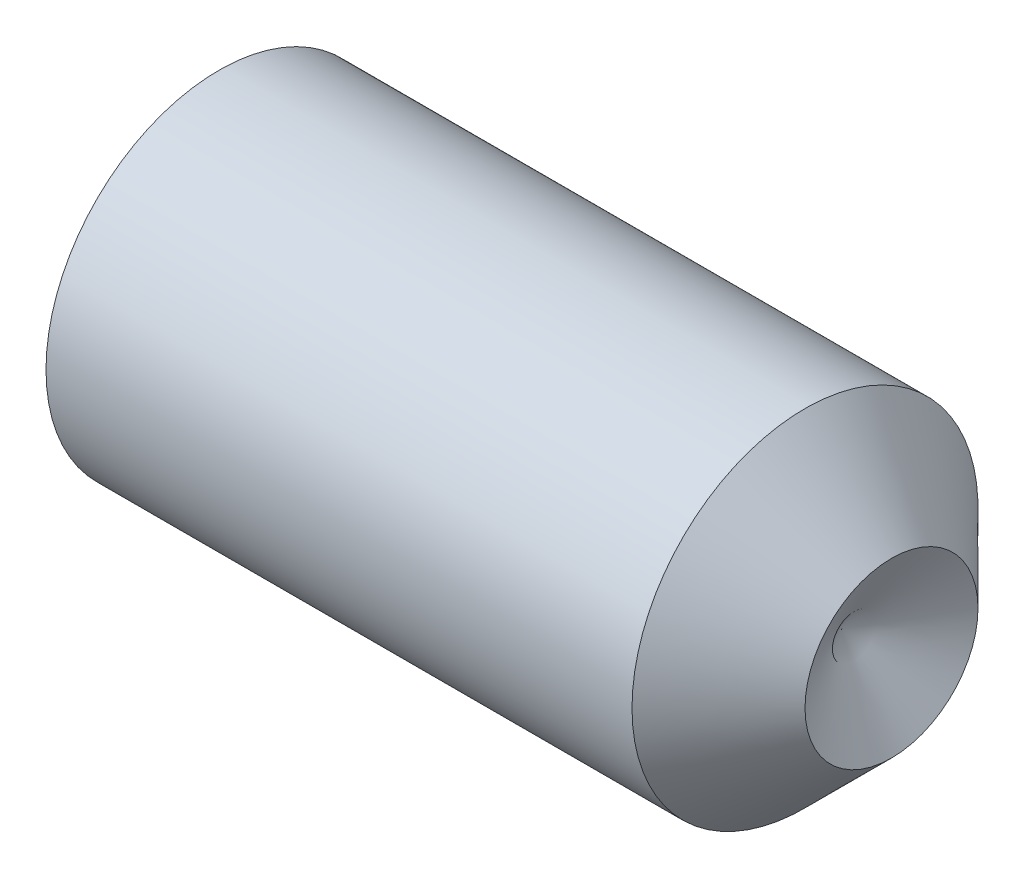
from build123d import *

# Parameters (mm, degrees)
HEX_2_DEPTH = 2.5


with BuildPart() as part:
    # BodySke → BaseBody (revolve)
    with BuildSketch(Plane.XY):
        Polygon((0, 0), (0, 1.61), (0.225166605, 2), (7, 2), (8, 1), (7.422649731, 0), align=None)
    revolve(axis=Axis((-12.7, 0, 0), (1, 0, 0)))

    # Sketch2 → Hex 2 (cut)
    with BuildSketch(Plane.ZY):
        Polygon((0.577350269, 1), (-0.577350269, 1), (-1.154700538, 0), (-0.577350269, -1), (0.577350269, -1), (1.154700538, 0), align=None)
    extrude(amount=-HEX_2_DEPTH, mode=Mode.SUBTRACT)


solid = part.part
